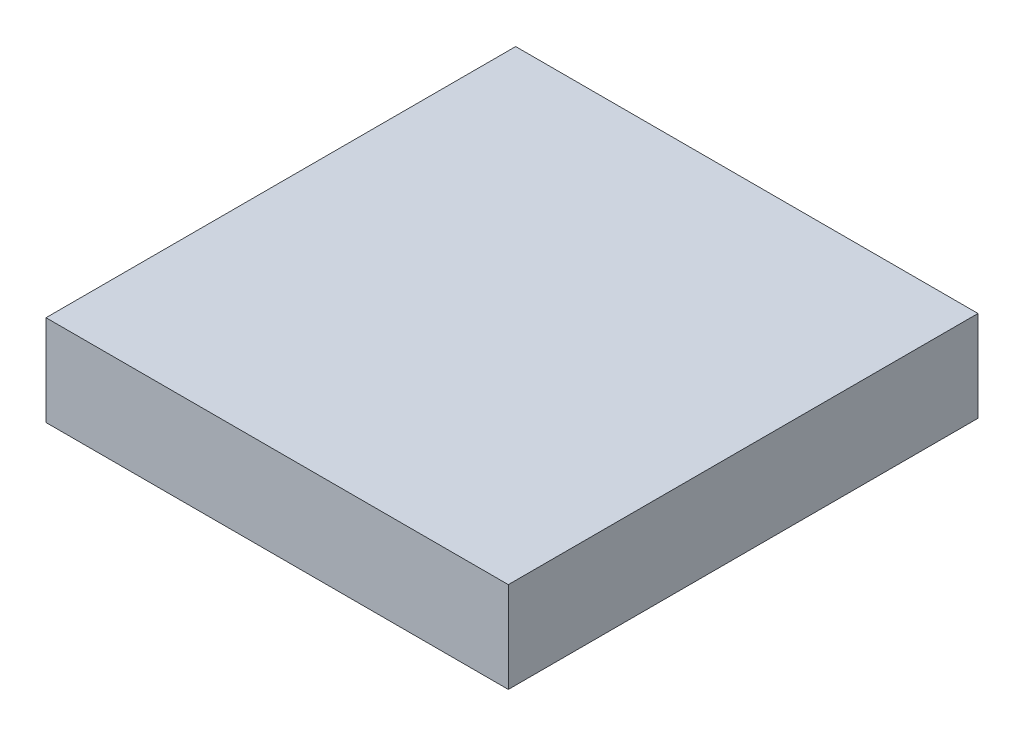
from build123d import *

# Parameters (mm, degrees)
SKETCH1_W           = 88.1
SKETCH1_H           = 89.499999999
BOSS_EXTRUDE1_DEPTH = 17.3


with BuildPart() as part:
    # Sketch1 → Boss-Extrude1 (new body)
    with BuildSketch(Plane(origin=(0, 0, 0), x_dir=(1, 0, 0), z_dir=(0, 1, 0))):
        with Locations((16.51875, -17.046679687)):
            Rectangle(SKETCH1_W, SKETCH1_H)
    extrude(amount=BOSS_EXTRUDE1_DEPTH)


solid = part.part
